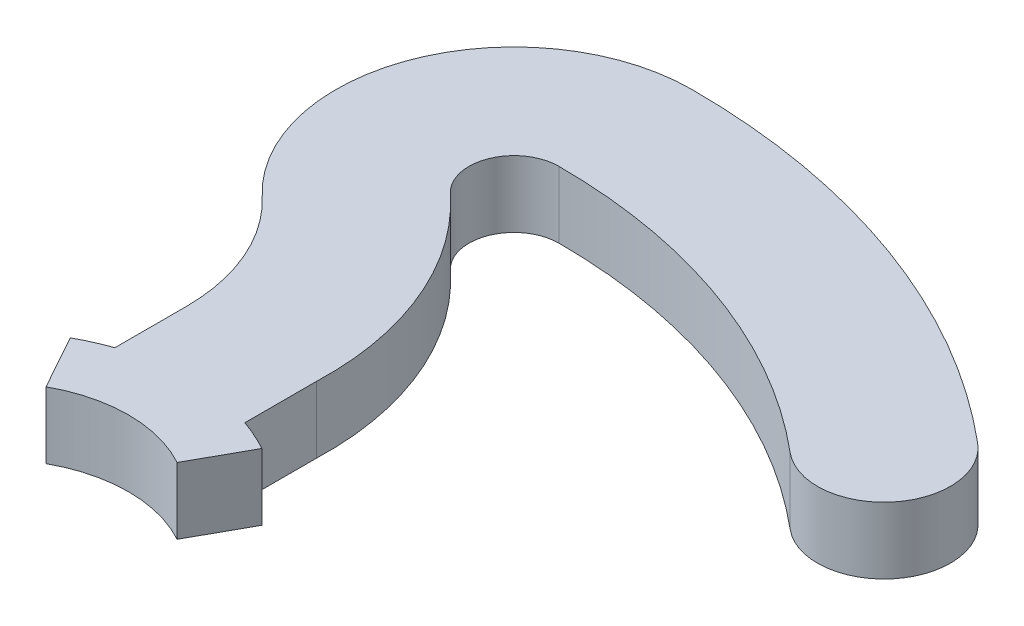
from build123d import *

# Parameters (mm, degrees)
BOSS_EXTRUDE1_DEPTH = 3.175


with BuildPart() as part:
    # Sketch8 → Boss-Extrude1 (new, symmetric)
    with BuildSketch(Plane(origin=(0, 0, 0), x_dir=(1, 0, 0), z_dir=(0, 1, 0))):
        with BuildLine():
            Line((-6.254044101, 11.282594222), (-9.138661342, 16.48658148))
            ThreePointArc((-9.138661342, 16.48658148), (-7.69744661, 17.206737508), (-6.2, 17.80119378))
            Line((-6.2, 17.80119378), (-6.2, 24.631686909))
            ThreePointArc((-6.2, 24.631686909), (-7.626220631, 31.546787733), (-11.672110257, 37.333280783))
            ThreePointArc((-11.672110257, 37.333280783), (-15.789036104, 55.963427524), (0, 66.675))
            ThreePointArc((0, 66.675), (22.804193056, 62.654005491), (42.857863876, 51.076013245))
            ThreePointArc((42.857863876, 51.076013245), (43.640544768, 42.12992971), (34.694461233, 41.347248817))
            ThreePointArc((34.694461233, 41.347248817), (18.460537236, 50.719909207), (0, 53.975))
            ThreePointArc((0, 53.975), (-3.988447659, 51.269163755), (-2.948476431, 46.563026873))
            ThreePointArc((-2.948476431, 46.563026873), (4.019706834, 36.595971198), (6.2, 24.631686909))
            Line((6.2, 24.631686909), (6.2, 17.80119378))
            ThreePointArc((6.2, 17.80119378), (7.69744661, 17.206737508), (9.138661342, 16.48658148))
            Line((9.138661342, 16.48658148), (6.254044101, 11.282594222))
            ThreePointArc((6.254044101, 11.282594222), (0, 12.9), (-6.254044101, 11.282594222))
        make_face()
    extrude(amount=BOSS_EXTRUDE1_DEPTH, both=True)


solid = part.part
